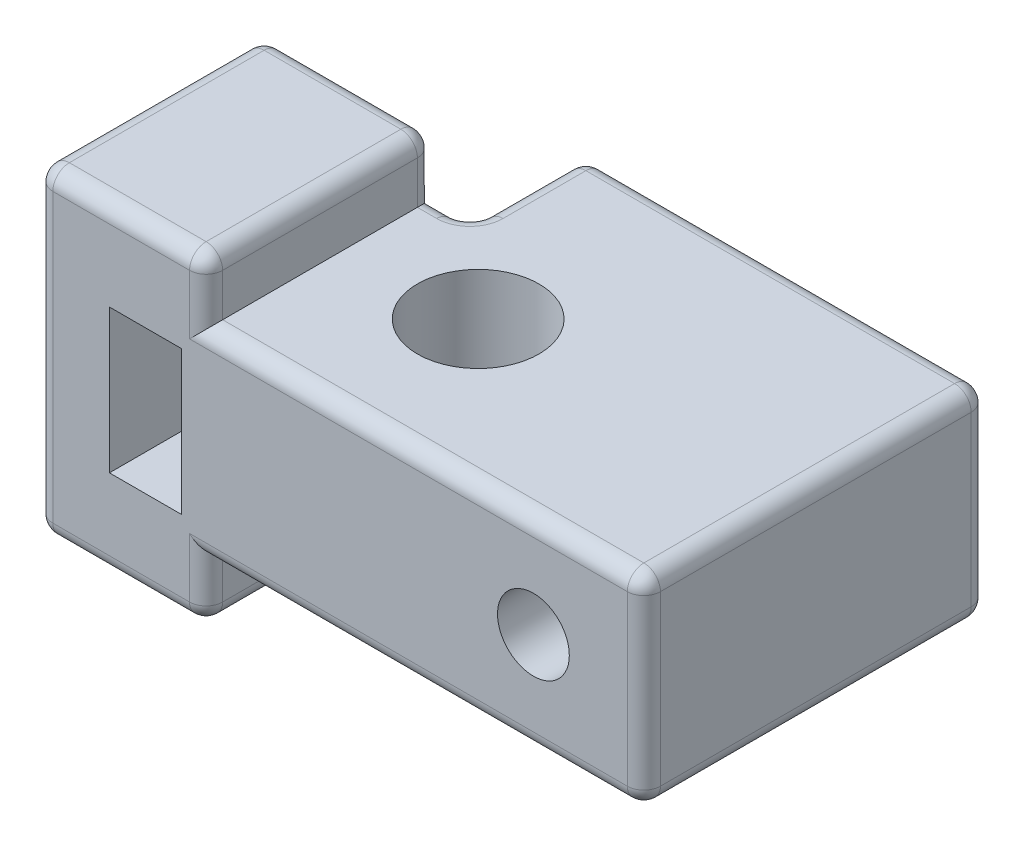
from build123d import *

# Parameters (mm, degrees)
SKETCH1_R           = 2.794
BOSS_EXTRUDE1_DEPTH = 4.6355
SKETCH2_W           = 10.4775
SKETCH2_H           = 9.271
BOSS_EXTRUDE2_DEPTH = 2.54
SKETCH3_W           = 7.8105
SKETCH3_H           = 10.4775
BOSS_EXTRUDE3_DEPTH = 7.366
SKETCH4_W           = 3.302
SKETCH4_H           = 6.604
CUT_EXTRUDE1_DEPTH  = 10.4775
SKETCH5_R           = 1.651
CUT_EXTRUDE2_DEPTH  = 15.8115
FILLET1_R           = 0.762


with BuildPart() as part:
    # Sketch1 → Boss-Extrude1 (new body, symmetric)
    with BuildSketch(Plane(origin=(0, 0, 0), x_dir=(1, 0, 0), z_dir=(0, 1, 0))):
        Polygon((-11.1125, 3.81), (-4.191, 3.81), (-4.191, 9.144), (14.2875, 9.144), (14.2875, -6.6675), (-11.1125, -6.6675), align=None)
        Circle(SKETCH1_R, mode=Mode.SUBTRACT)
    extrude(amount=BOSS_EXTRUDE1_DEPTH, both=True)

    # Sketch2 → Boss-Extrude2 (add)
    with BuildSketch(Plane.ZY.offset(11.1125)):
        with Locations((1.42875, 0)):
            Rectangle(SKETCH2_W, SKETCH2_H)
    extrude(amount=BOSS_EXTRUDE2_DEPTH)

    # Sketch3 → Boss-Extrude3 (add, symmetric)
    with BuildSketch(Plane(origin=(0, 0, 0), x_dir=(1, 0, 0), z_dir=(0, 1, 0))):
        with Locations((-9.74725, -1.42875)):
            Rectangle(SKETCH3_W, SKETCH3_H)
    extrude(amount=BOSS_EXTRUDE3_DEPTH, both=True)

    # Sketch4 → Cut-Extrude1 (cut)
    with BuildSketch(Plane(origin=(0, 0, -3.81), x_dir=(-1, 0, 0), z_dir=(0, 0, -1))):
        with Locations((8.636, 0)):
            Rectangle(SKETCH4_W, SKETCH4_H)
    extrude(amount=-CUT_EXTRUDE1_DEPTH, mode=Mode.SUBTRACT)

    # Sketch5 → Cut-Extrude2 (cut)
    with BuildSketch(Plane.XY.offset(6.6675)):
        with Locations((9.2075, 0)):
            Circle(SKETCH5_R)
    extrude(amount=-CUT_EXTRUDE2_DEPTH, mode=Mode.SUBTRACT)

    # Fillet1
    fillet1_edges = [part.edges().sort_by_distance(p)[0] for p in [
        (14.2875, 4.6355, -1.23825),
        (-4.191, 0, -3.81),
        (-4.191, 0, -9.144),
        (14.2875, 0, -9.144),
        (14.2875, 0, 6.6675),
        (5.04825, 4.6355, -9.144),
        (-4.191, 4.6355, -6.477),
        (-5.0165, 4.6355, -3.81),
        (-13.6525, 0, -3.81),
        (-13.6525, 0, 6.6675),
        (4.22275, -4.6355, 6.6675),
        (4.22275, 4.6355, 6.6675),
        (-5.842, 6.00075, 6.6675),
        (-5.842, 6.00075, -3.81),
        (-5.842, -6.00075, 6.6675),
        (-5.842, -7.366, 1.42875),
        (-5.842, -6.00075, -3.81),
        (-9.74725, -7.366, -3.81),
        (-13.6525, -7.366, 1.42875),
        (-9.74725, -7.366, 6.6675),
        (-5.842, 7.366, 1.42875),
        (-9.74725, 7.366, -3.81),
        (-13.6525, 7.366, 1.42875),
        (-9.74725, 7.366, 6.6675),
        (-5.0165, -4.6355, -3.81),
        (-4.191, -4.6355, -6.477),
        (5.04825, -4.6355, -9.144),
        (14.2875, -4.6355, -1.23825),
    ]]
    fillet(fillet1_edges, radius=FILLET1_R)


solid = part.part
